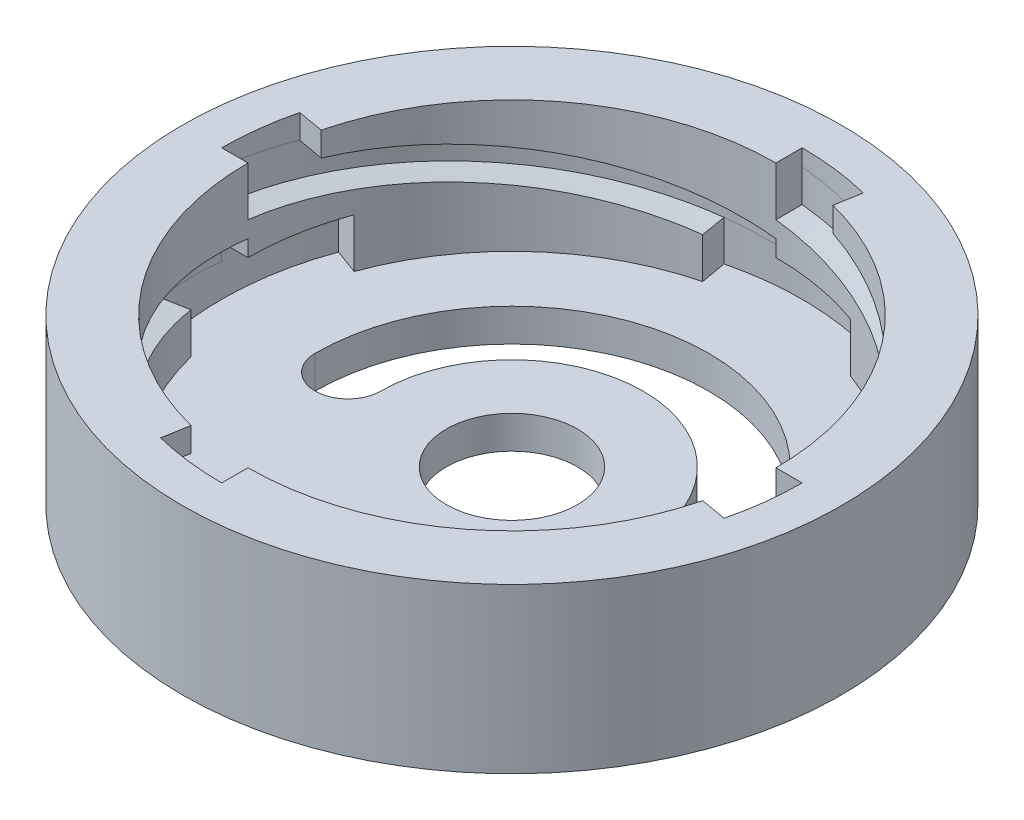
from build123d import *

# Parameters (mm, degrees)
SKETCH1_R              = 16.1
SKETCH1_R_2            = 4
BOSS_EXTRUDE1_DEPTH    = 2
SKETCH2_R              = 20.1
SKETCH2_R_2            = 16.1
BOSS_EXTRUDE2_DEPTH    = 10
CUT_SWEEP2_PITCH       = 12
CUT_SWEEP2_HEIGHT      = 3
CUT_SWEEP2_RADIUS      = 16.1
CUT_SWEEP2_START_ANGLE = -90
SKETCH35_W             = 3.2
SKETCH35_H             = 2
CIRPATTERN3_COUNT      = 4
CUT_EXTRUDE1_DEPTH     = 2
CIRPATTERN4_COUNT      = 4
CUT_EXTRUDE4_DEPTH     = 3
CIRPATTERN5_COUNT      = 4


with BuildPart() as part:
    # Sketch1 → Boss-Extrude1 (new body)
    with BuildSketch(Plane(origin=(0, 0, 0), x_dir=(1, 0, 0), z_dir=(0, 1, 0))):
        Circle(SKETCH1_R)
        Circle(SKETCH1_R_2, mode=Mode.SUBTRACT)
        with BuildLine():
            ThreePointArc((12, 0), (0, 12), (-12, 0))
            ThreePointArc((-12, 0), (-10, -2), (-8, 0))
            ThreePointArc((-8, 0), (0, 8), (8, 0))
            ThreePointArc((8, 0), (10, -2), (12, 0))
        make_face(mode=Mode.SUBTRACT)
    extrude(amount=BOSS_EXTRUDE1_DEPTH)

    # Sketch2 → Boss-Extrude2 (add)
    with BuildSketch(Plane(origin=(0, 0, 0), x_dir=(1, 0, 0), z_dir=(0, 1, 0))):
        Circle(SKETCH2_R)
        Circle(SKETCH2_R_2, mode=Mode.SUBTRACT)
    extrude(amount=BOSS_EXTRUDE2_DEPTH)

    # Cut-Sweep2: sweep along a helix
    with BuildLine() as cut_sweep2_path:
        add(Helix(CUT_SWEEP2_PITCH, CUT_SWEEP2_HEIGHT, CUT_SWEEP2_RADIUS, center=(0, 8, 0), direction=(0, -1, 0), mode=Mode.PRIVATE).rotate(Axis((0, 8, 0), (0, -1, 0)), CUT_SWEEP2_START_ANGLE))
    # Sketch35 → Cut-Sweep2 (sweep, cut)
    with BuildSketch(Plane.XY):
        with Locations((-16.1, 8)):
            Rectangle(SKETCH35_W, SKETCH35_H)
    cut_sweep2 = sweep(path=cut_sweep2_path.line, is_frenet=True, mode=Mode.SUBTRACT)

    # CirPattern3: Cut-Sweep2 ×4 about axis
    cirpattern3_axis = Axis((0, 2, 0), (0, -1, 0))
    for i in range(1, CIRPATTERN3_COUNT):
        add(cut_sweep2.rotate(cirpattern3_axis, i * 360 / CIRPATTERN3_COUNT), mode=Mode.SUBTRACT)

    # Sketch36 → Cut-Extrude1 (cut)
    with BuildSketch(Plane(origin=(0, 10, 0), x_dir=(1, 0, 0), z_dir=(0, 1, 0))):
        with BuildLine():
            Line((-17.7, 0), (-16.1, 0))
            ThreePointArc((-16.1, 0), (-15.975293425, 2), (-15.60310559, 3.969017))
            Line((-15.60310559, 3.969017), (-17.182789415, 4.247557879))
            ThreePointArc((-17.182789415, 4.247557879), (-17.570221579, 2.139465747), (-17.7, 0))
        make_face()
    cut_extrude1 = extrude(amount=-CUT_EXTRUDE1_DEPTH, mode=Mode.SUBTRACT)

    # CirPattern4: Cut-Extrude1 ×4 about axis
    cirpattern4_axis = Axis((0, 0, 0), (0, 1, 0))
    for i in range(1, CIRPATTERN4_COUNT):
        add(cut_extrude1.rotate(cirpattern4_axis, i * 360 / CIRPATTERN4_COUNT), mode=Mode.SUBTRACT)

    # Sketch37 → Cut-Extrude4 (cut)
    with BuildSketch(Plane(origin=(0, 2, 0), x_dir=(1, 0, 0), z_dir=(0, 1, 0))):
        with BuildLine():
            Line((-15.129051195, 5.506524308), (-16.632559388, 6.053756537))
            ThreePointArc((-16.632559388, 6.053756537), (-17.674804761, 0.944074504), (-17.182789415, -4.247557879))
            Line((-17.182789415, -4.247557879), (-15.60310559, -3.969017))
            ThreePointArc((-15.60310559, -3.969017), (-16.079889176, 0.804465085), (-15.129051195, 5.506524308))
        make_face()
    cut_extrude4 = extrude(amount=CUT_EXTRUDE4_DEPTH, mode=Mode.SUBTRACT)

    # CirPattern5: Cut-Extrude4 ×4 about axis
    cirpattern5_axis = Axis((0, 0, 0), (0, 1, 0))
    for i in range(1, CIRPATTERN5_COUNT):
        add(cut_extrude4.rotate(cirpattern5_axis, i * 360 / CIRPATTERN5_COUNT), mode=Mode.SUBTRACT)


solid = part.part
